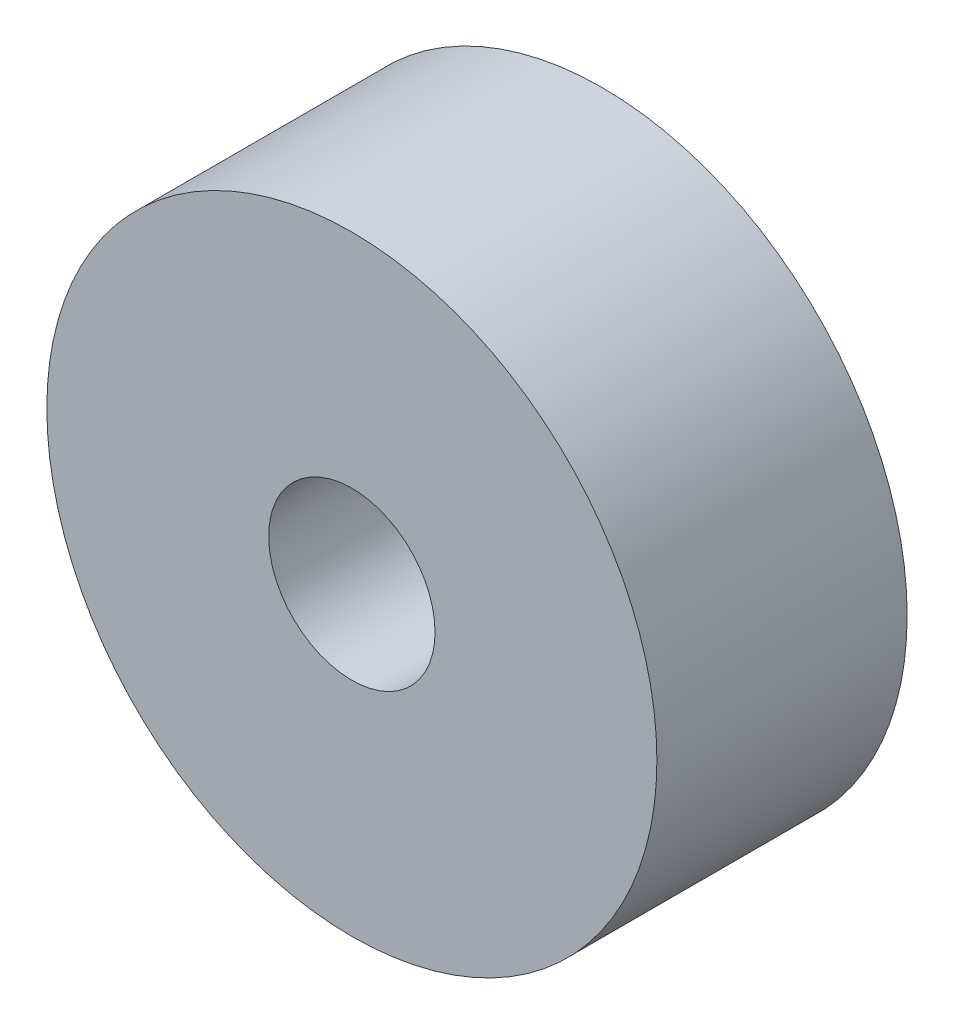
from build123d import *

# Parameters (mm, degrees)
SKETCH_1_R      = 22
SKETCH_1_R_2    = 7.9
EXTRUDE_1_DEPTH = 9.05
SKETCH_2_R      = 22
SKETCH_2_R_2    = 6
EXTRUDE_2_DEPTH = 9


with BuildPart() as part:
    # Эскиз1 → Бобышка-Вытянуть1 (new body)
    with BuildSketch(Plane.XY):
        Circle(SKETCH_1_R)
        Circle(SKETCH_1_R_2, mode=Mode.SUBTRACT)
    extrude(amount=EXTRUDE_1_DEPTH)

    # Эскиз2 → Бобышка-Вытянуть2 (add)
    with BuildSketch(Plane.XY.offset(9.05)):
        Circle(SKETCH_2_R)
        with Locations((-0.000227029, 0.000150284)):
            Circle(SKETCH_2_R_2, mode=Mode.SUBTRACT)
    extrude(amount=EXTRUDE_2_DEPTH)


solid = part.part
